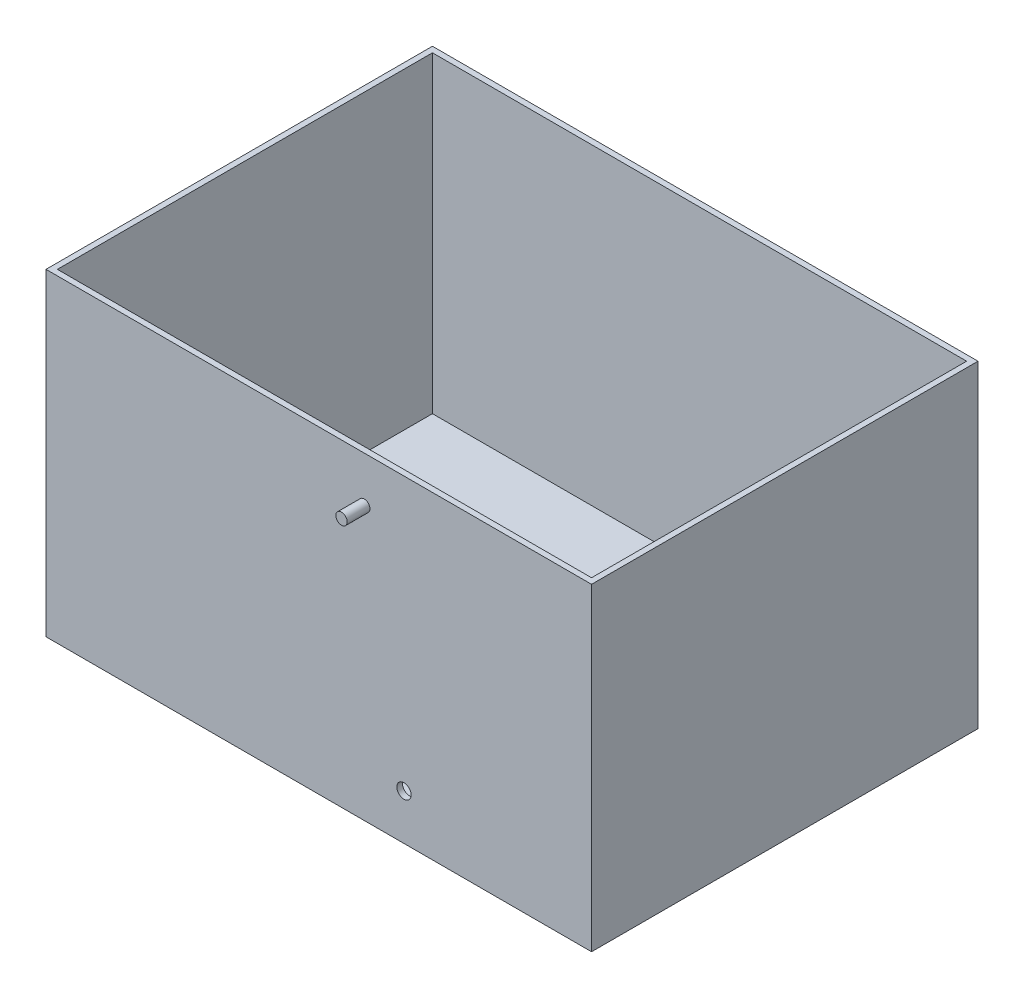
from build123d import *

# Parameters (mm, degrees)
SKETCH1_W               = 298.45
SKETCH1_H               = 209.55
BOSS_EXTRUDE1_DEPTH     = 3.175
SKETCH1_3_W             = 304.8
SKETCH1_3_H             = 215.9
SKETCH1_3_W_2           = 298.45
SKETCH1_3_H_2           = 209.55
BOSS_EXTRUDE2_DEPTH     = 177.8
SKETCH2_R               = 3.175
BOSS_EXTRUDE3_DEPTH     = 12.7
CUT_EXTRUDE1_DEPTH      = 319.514379581
CUT_EXTRUDE1_DEPTH_BACK = 319.514379581
SKETCH2_3_R             = 4


with BuildPart() as part:
    # Sketch1 → Boss-Extrude1 (new body)
    with BuildSketch(Plane(origin=(0, 0, 0), x_dir=(1, 0, 0), z_dir=(0, 1, 0))):
        Rectangle(SKETCH1_W, SKETCH1_H)
    extrude(amount=BOSS_EXTRUDE1_DEPTH)

    # Sketch1_3 → Boss-Extrude2 (add)
    with BuildSketch(Plane(origin=(0, 0, 0), x_dir=(1, 0, 0), z_dir=(0, 1, 0))):
        Rectangle(SKETCH1_3_W, SKETCH1_3_H)
        Rectangle(SKETCH1_3_W_2, SKETCH1_3_H_2, mode=Mode.SUBTRACT)
    extrude(amount=BOSS_EXTRUDE2_DEPTH)

    # Sketch2 → Boss-Extrude3 (add)
    with BuildSketch(Plane.XY.offset(107.95)):
        with Locations((25.4, 152.4)):
            Circle(SKETCH2_R)
    boss_extrude3 = extrude(amount=BOSS_EXTRUDE3_DEPTH)

    # Sketch2_3 → Cut-Extrude1 (cut, two sides: drawn at the far end of the back side and taken through both)
    with BuildSketch(Plane.XY.offset(107.95).offset(-CUT_EXTRUDE1_DEPTH_BACK)):
        with Locations((47.6, 25.4)):
            Circle(SKETCH2_3_R)
    extrude(amount=CUT_EXTRUDE1_DEPTH + CUT_EXTRUDE1_DEPTH_BACK, mode=Mode.SUBTRACT)

    # Mirror1: Boss-Extrude3 across plane
    add(boss_extrude3.mirror(Plane.XY))


solid = part.part
